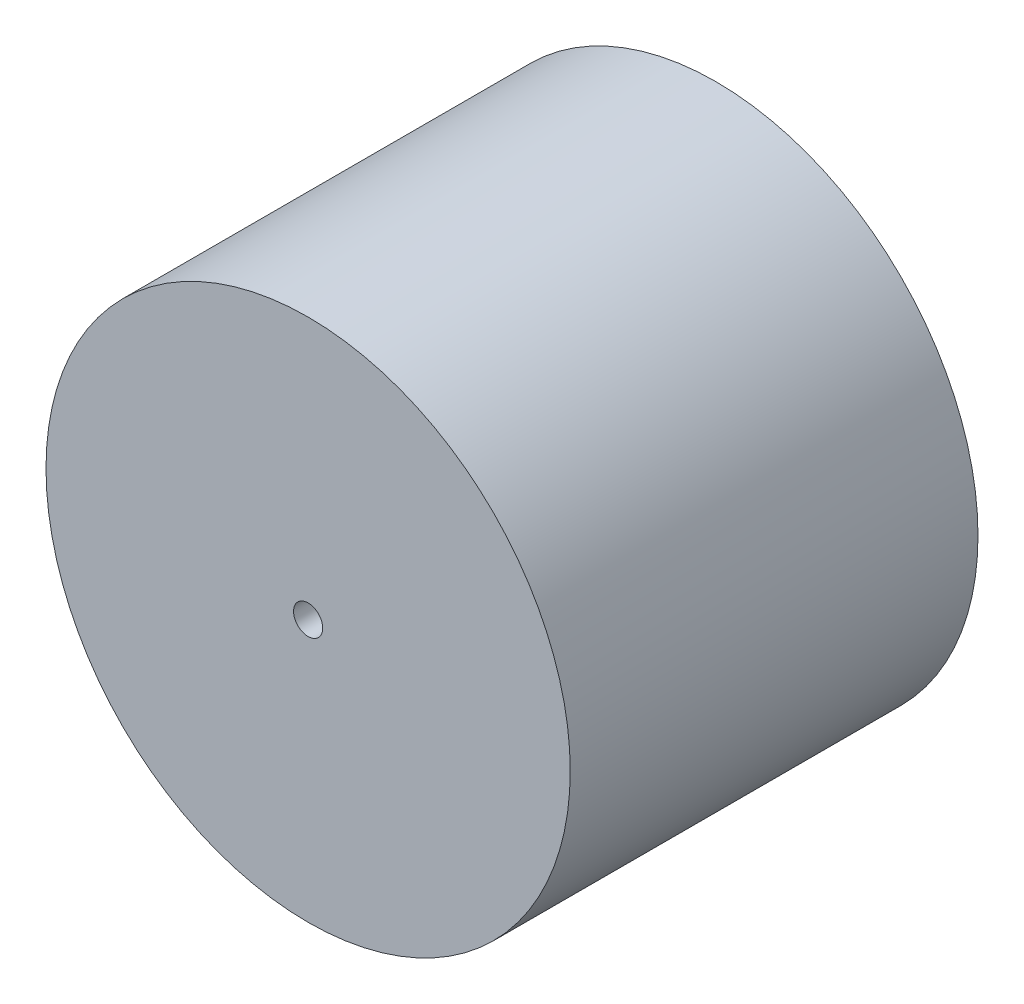
from build123d import *

# Parameters (mm, degrees)
SKETCH1_R           = 9
BOSS_EXTRUDE1_DEPTH = 7
SKETCH2_R           = 0.5
CUT_EXTRUDE1_DEPTH  = 14


with BuildPart() as part:
    # Sketch1 → Boss-Extrude1 (new body, symmetric)
    with BuildSketch(Plane.XY):
        with Locations((-19.447070122, 20.520011922)):
            Circle(SKETCH1_R)
    extrude(amount=BOSS_EXTRUDE1_DEPTH, both=True)

    # Sketch2 → Cut-Extrude1 (cut)
    with BuildSketch(Plane.XY.offset(7)):
        with Locations((-19.447070122, 20.520011922)):
            Circle(SKETCH2_R)
    extrude(amount=-CUT_EXTRUDE1_DEPTH, mode=Mode.SUBTRACT)


solid = part.part
